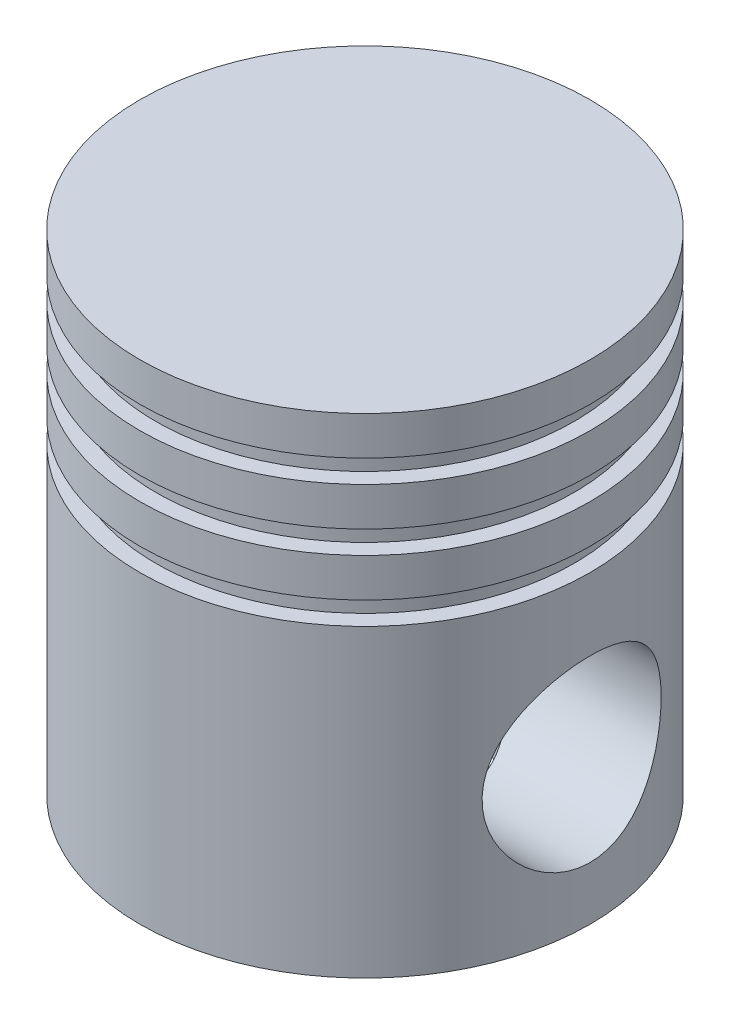
from build123d import *

# Parameters (mm, degrees)
SKETCH4_R          = 16.9
CUT_EXTRUDE1_DEPTH = 42.5
SKETCH5_W          = 36
SKETCH5_H          = 40
SKETCH6_R          = 19
CUT_EXTRUDE2_DEPTH = 45


with BuildPart() as part:
    # Sketch2 → Revolve1 (revolve)
    with BuildSketch(Plane(origin=(0, 0, 0), x_dir=(0, 0, -1), z_dir=(1, 0, 0))):
        Polygon((39.5, 25.428946917), (39.5, 21.128946917), (42.5, 21.128946917), (42.5, 13.828946917), (39.5, 13.828946917), (39.5, 9.528946917), (42.5, 9.528946917), (42.5, -47.971053083), (0, -47.971053083), (0, 44.328946917), (42.5, 44.328946917), (42.5, 37.028946917), (39.5, 37.028946917), (39.5, 32.728946917), (42.5, 32.728946917), (42.5, 25.428946917), align=None)
    revolve(axis=Axis((0, -52.221053083, 0), (0, 1, 0)))

    # Sketch4 → Cut-Extrude1 (cut, symmetric)
    with BuildSketch(Plane(origin=(0, 0, 0), x_dir=(0, 0, -1), z_dir=(1, 0, 0))):
        with Locations((0, -20.971053083)):
            Circle(SKETCH4_R)
    extrude(amount=CUT_EXTRUDE1_DEPTH, both=True, mode=Mode.SUBTRACT)

    # Sketch5 → Cut-Revolve1 (revolve, cut)
    with BuildSketch(Plane(origin=(0, 0, 0), x_dir=(0, 0, -1), z_dir=(1, 0, 0))):
        with Locations((-18, 17.028946917)):
            Rectangle(SKETCH5_W, SKETCH5_H)
    revolve(axis=Axis((0, -52.221053083, 0), (0, 1, 0)), mode=Mode.SUBTRACT)

    # Sketch6 → Cut-Extrude2 (cut)
    with BuildSketch(Plane.XZ.offset(47.971053083)):
        Circle(SKETCH6_R)
    extrude(amount=-CUT_EXTRUDE2_DEPTH, mode=Mode.SUBTRACT)


solid = part.part
